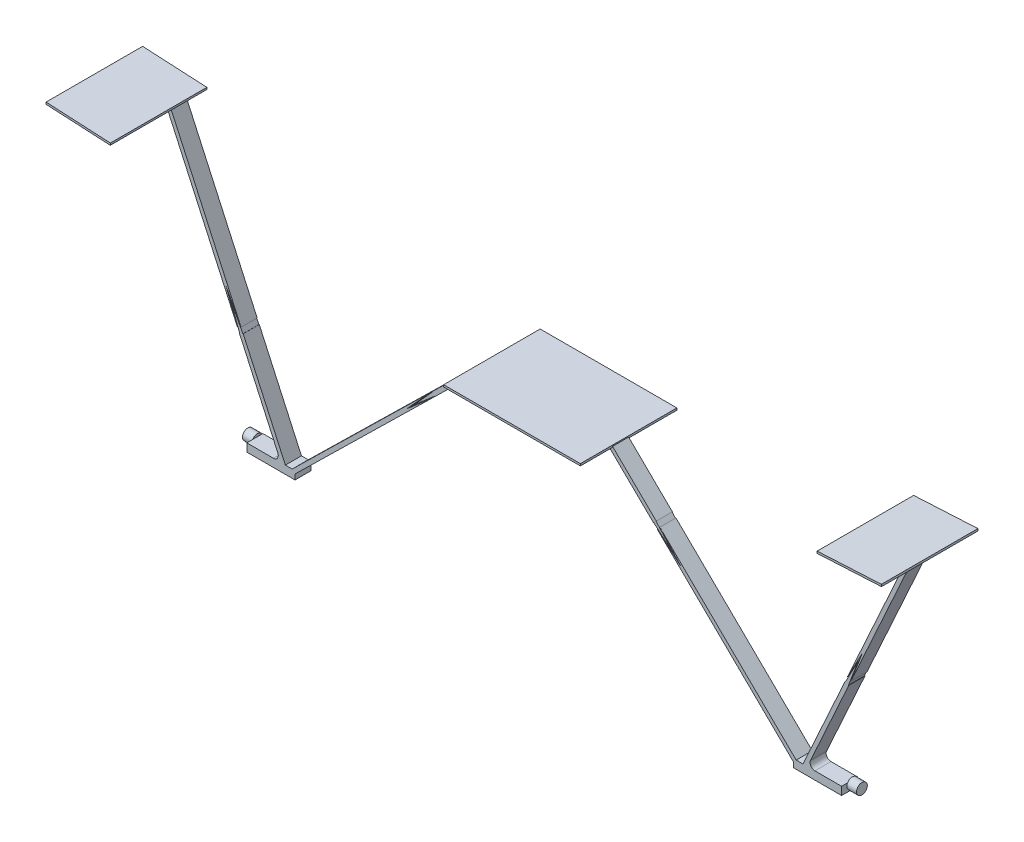
from build123d import *

# Parameters (mm, degrees)
BOSS_EXTRUDE1_DEPTH  = 38.1
BOSS_EXTRUDE2_DEPTH  = 76.2
SKETCH1_6_W          = 38.1
SKETCH1_6_H          = 6.35
BOSS_EXTRUDE8_DEPTH  = 12.7
BOSS_EXTRUDE9_DEPTH  = 12.7
BOSS_EXTRUDE10_DEPTH = 12.7
SKETCH2_R            = 4.2625
BOSS_EXTRUDE11_DEPTH = 7.62
FILLET1_R            = 3.81
CUT_EXTRUDE1_DEPTH   = 383.370861178


with BuildPart() as part:
    # Sketch1 → Boss-Extrude1 (new, symmetric)
    with BuildSketch(Plane.XY):
        Polygon((0, -28.575), (50.8, -28.575), (53.975, -28.575), (53.975, -30.1625), (0, -30.1625), align=None)
    extrude(amount=BOSS_EXTRUDE1_DEPTH, both=True)



with BuildPart() as body_2:
    # Sketch1_4 → Boss-Extrude2 (new body)
    with BuildSketch(Plane.XY):
        Polygon((279.01709201, 43.197666174), (279.100175341, 41.612341788), (329.830555706, 44.271008365), (329.747472376, 45.856332751), align=None)
    extrude(amount=BOSS_EXTRUDE2_DEPTH)


with BuildPart() as body_3:
    # Sketch1_6 → Boss-Extrude8 (new body)
    with BuildSketch(Plane.XY):
        with Locations((215.764893617, -174.625)):
            Rectangle(SKETCH1_6_W, SKETCH1_6_H)
    extrude(amount=BOSS_EXTRUDE8_DEPTH)


with BuildPart() as part_1:
    add(part.part)

    add(body_3.part)  # Boss-Extrude9 merges body 3
    # Sketch1_7 → Boss-Extrude9 (add)
    with BuildSketch(Plane.XY):
        Polygon((53.975, -30.1625), (50.152203206, -30.1625), (196.714893617, -173.671801028), (196.714893617, -171.45), (198.983967007, -171.45), (53.975, -29.462053139), align=None)
    extrude(amount=BOSS_EXTRUDE9_DEPTH)


    add(body_2.part)  # Boss-Extrude10 merges body 2
    # Sketch1_8 → Boss-Extrude10 (add)
    with BuildSketch(Plane.XY):
        Polygon((301.854344952, 42.804837287), (204.345749685, -171.45), (207.834092561, -171.45), (305.427921483, 42.992120497), align=None)
    extrude(amount=BOSS_EXTRUDE10_DEPTH)

    # Sketch2 → Boss-Extrude11 (add)
    with BuildSketch(Plane(origin=(234.814893617, 0, 0), x_dir=(0, 0, -1), z_dir=(1, 0, 0))):
        with Locations((-4.2625, -173.5375)):
            Circle(SKETCH2_R)
    extrude(amount=BOSS_EXTRUDE11_DEPTH)

    # Fillet1
    fillet1_edges = [part_1.edges().sort_by_distance(p)[0] for p in [
        (305.427921483, 42.992120497, 6.35),
        (301.854344952, 42.804837287, 6.35),
        (207.834092561, -171.45, 6.35),
        (50.152203206, -30.1625, 6.35),
    ]]
    fillet(fillet1_edges, radius=FILLET1_R)

    # Sketch3 → Cut-Extrude1 (cut, through all)
    with BuildSketch(Plane.XY.offset(38.1)):
        Polygon((86.104765819, -65.715259435), (108.391026486, -84.966213434), (88.675205699, -63.090129344), (88.303789567, -63.424868133), (102.66378973, -79.358294111), (86.431612015, -65.33687925), align=None)
        Polygon((237.859879225, -98.412038476), (247.945332781, -79.481446973), (240.295481696, -99.520495016), (240.762601933, -99.698816872), (251.265602721, -72.185845043), (237.418597665, -98.176941507), align=None)
    extrude(amount=-CUT_EXTRUDE1_DEPTH, mode=Mode.SUBTRACT)


with BuildPart() as cut_extrude1_piece_1:
    # of the separate pieces the step leaves, piece 1, a body of its own (cut_extrude1_pieces)
    add(part_1.part.solids().sort_by_distance((237.639238445, -98.294489992, 0))[0])


with BuildPart() as cut_extrude1_piece_2:
    # of the separate pieces the step leaves, piece 2, a body of its own (cut_extrude1_pieces)
    add(part_1.part.solids().sort_by_distance((295.587895579, 42.476426591, 0))[0])


with BuildPart() as cut_extrude1_piece_3:
    # of the separate pieces the step leaves, piece 3, a body of its own (cut_extrude1_pieces)
    add(part_1.part.solids().sort_by_distance((88.489497633, -63.257498738, 0))[0])

    # Mirror1: Cut-Extrude1 piece 3 across plane


with BuildPart() as cut_extrude1_piece_3_1:
    add(cut_extrude1_piece_3.part)
    add(cut_extrude1_piece_3.part.mirror(Plane(origin=(0, 0, 0), x_dir=(0, 0, 1), z_dir=(1, 0, 0))))


with BuildPart() as body_4:
    # Mirror2: mirrored copy
    add(cut_extrude1_piece_1.part.mirror(Plane(origin=(0, 0, 0), x_dir=(0, 0, 1), z_dir=(1, 0, 0))))


with BuildPart() as body_5:
    # Mirror2 2: mirrored copy
    add(cut_extrude1_piece_2.part.mirror(Plane(origin=(0, 0, 0), x_dir=(0, 0, 1), z_dir=(1, 0, 0))))


solid = Compound([cut_extrude1_piece_1.part, cut_extrude1_piece_2.part, cut_extrude1_piece_3_1.part, body_4.part, body_5.part])
